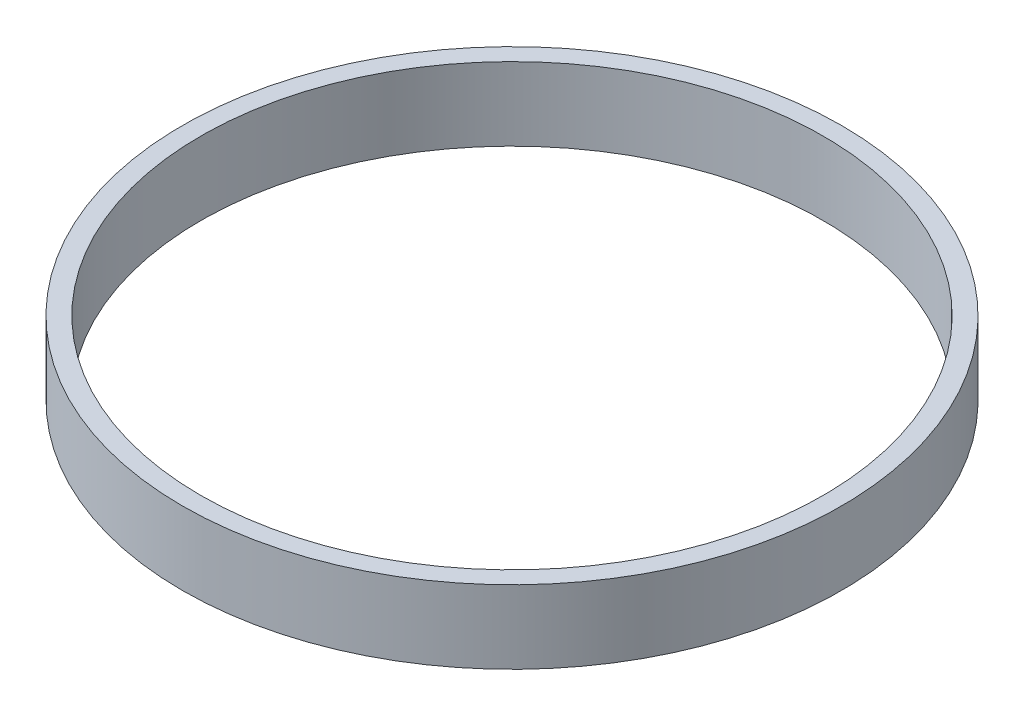
from build123d import *

# Parameters (mm, degrees)
SKETCH1_R           = 45
BOSS_EXTRUDE1_DEPTH = 10
SKETCH3_R           = 42.5
CUT_EXTRUDE1_DEPTH  = 20.35


with BuildPart() as part:
    # Sketch1 → Boss-Extrude1 (new body)
    with BuildSketch(Plane(origin=(0, 0, 0), x_dir=(1, 0, 0), z_dir=(0, 1, 0))):
        Circle(SKETCH1_R)
    extrude(amount=BOSS_EXTRUDE1_DEPTH)

    # Sketch3 → Cut-Extrude1 (cut)
    with BuildSketch(Plane(origin=(0, 10, 0), x_dir=(1, 0, 0), z_dir=(0, 1, 0))):
        Circle(SKETCH3_R)
    extrude(amount=-CUT_EXTRUDE1_DEPTH, mode=Mode.SUBTRACT)


solid = part.part
